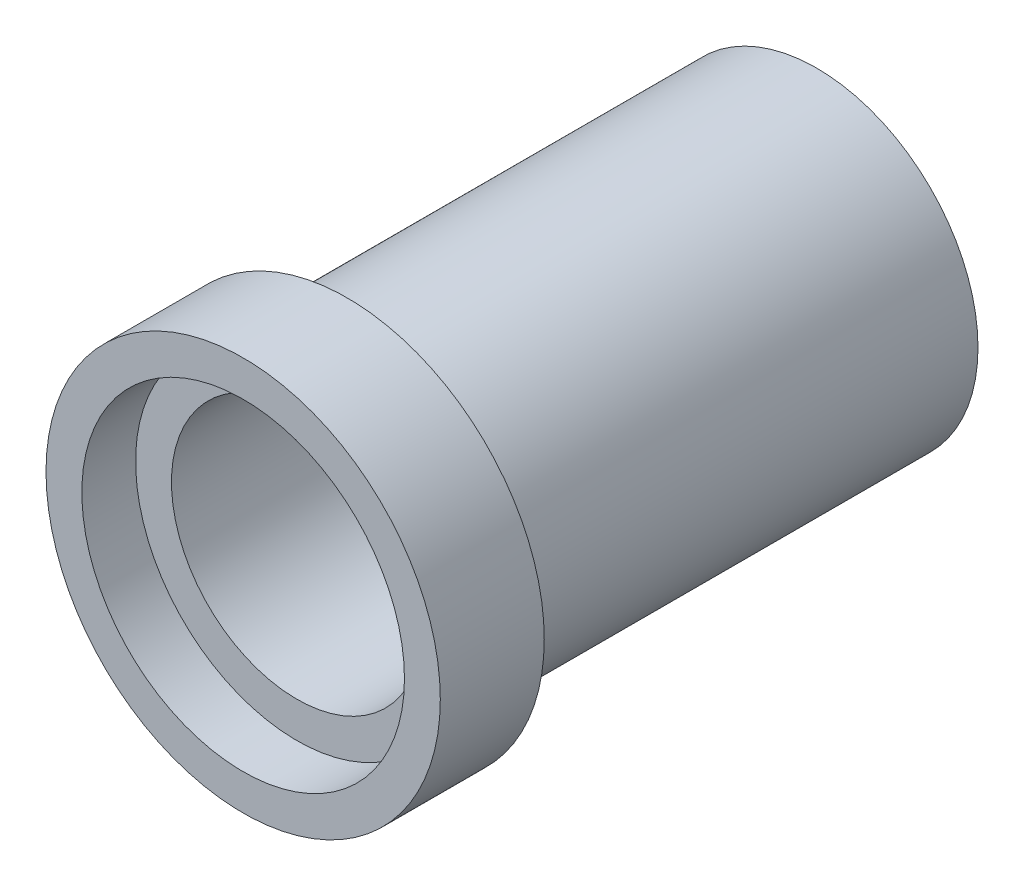
from build123d import *

# Parameters (mm, degrees)
SKETCH3_R           = 9
SKETCH3_R_2         = 7
BOSS_EXTRUDE1_DEPTH = 0.8


with BuildPart() as part:
    # Sketch2 → Revolve1 (revolve)
    with BuildSketch(Plane(origin=(0, 0, 0), x_dir=(0, 0, -1), z_dir=(1, 0, 0)), mode=Mode.PRIVATE) as revolve1_sk:
        Polygon((-16, 11), (-10.2, 11), (-10.2, 9), (16, 9), (16, 7), (-12.2, 7), (-12.2, 9), (-16, 9), align=None)
    revolve(revolve1_sk.sketch.rotate(Axis((0, 0, 152.237580052), (0, 0, -1)), 90), axis=Axis((0, 0, 152.237580052), (0, 0, -1)))  # turned: the seam where the file's is

    # Sketch3 → Boss-Extrude1 (add)
    with BuildSketch(Plane.XY.offset(12.2)):
        Circle(SKETCH3_R)
        Circle(SKETCH3_R_2, mode=Mode.SUBTRACT)
    extrude(amount=BOSS_EXTRUDE1_DEPTH)


solid = part.part
